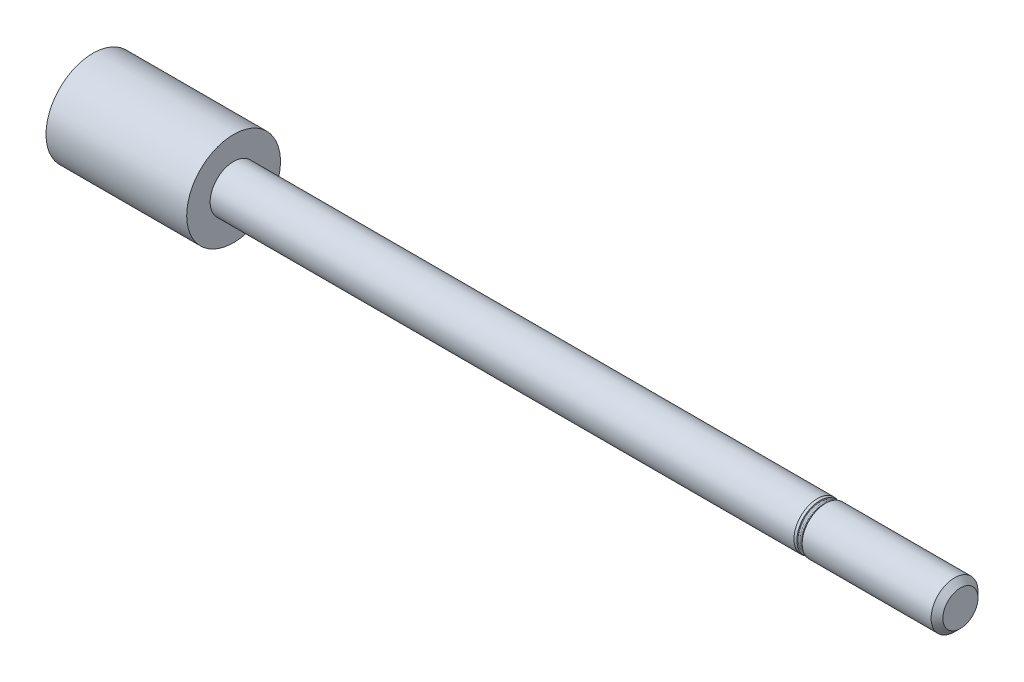
from build123d import *

# Parameters (mm, degrees)
SKETCH3_R = 4
P_L_DEPTH = 10


with BuildPart() as part:
    # Sketch1 → Revolve1 (revolve)
    with BuildSketch(Plane.XY):
        with BuildLine():
            Line((-30, 2), (19.8, 2))
            Line((19.8, 2), (20, 1.946410162))
            Line((20, 1.946410162), (20, 1.85))
            ThreePointArc((20, 1.85), (20.029289322, 1.779289322), (20.1, 1.75))
            Line((20.1, 1.75), (20.208578644, 1.75))
            ThreePointArc((20.208578644, 1.75), (20.246846987, 1.757612047), (20.279289322, 1.779289322))
            Line((20.279289322, 1.779289322), (20.5, 2))
            Line((20.5, 2), (31.5, 2))
            Line((31.5, 2), (32, 1.5))
            Line((32, 1.5), (32, 0))
            Line((32, 0), (-32, 0))
            Line((-32, 0), (-32, 4))
            Line((-32, 4), (-30, 4))
            Line((-30, 4), (-30, 2))
        make_face()
    revolve(axis=Axis((0, 0, 0), (1, 0, 0)))

    # Sketch3 → P-L (add)
    with BuildSketch(Plane.ZY.offset(32)):
        Circle(SKETCH3_R)
    extrude(amount=P_L_DEPTH)


solid = part.part
